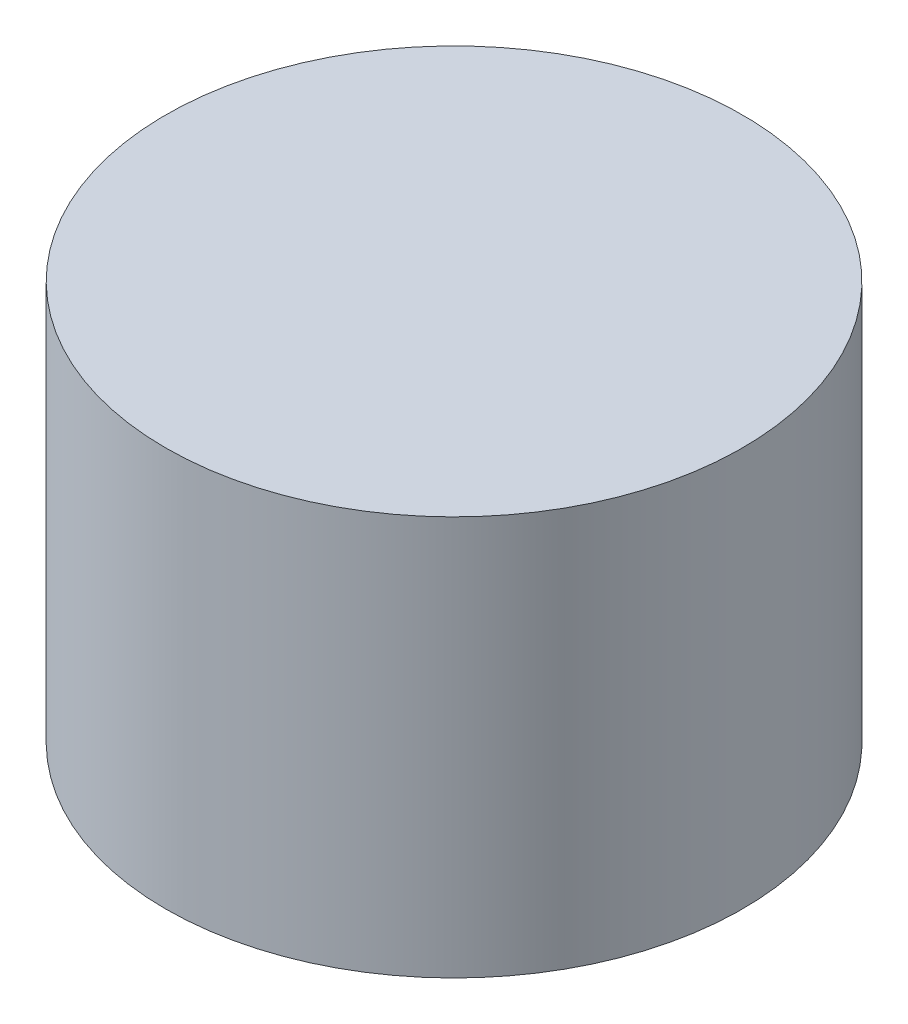
from build123d import *

# Parameters (mm, degrees)
SKETCH1_R           = 13
BOSS_EXTRUDE1_DEPTH = 18


with BuildPart() as part:
    # Sketch1 → Boss-Extrude1 (new body)
    with BuildSketch(Plane(origin=(0, 0, 0), x_dir=(1, 0, 0), z_dir=(0, 1, 0))):
        Circle(SKETCH1_R)
    extrude(amount=BOSS_EXTRUDE1_DEPTH)


solid = part.part
